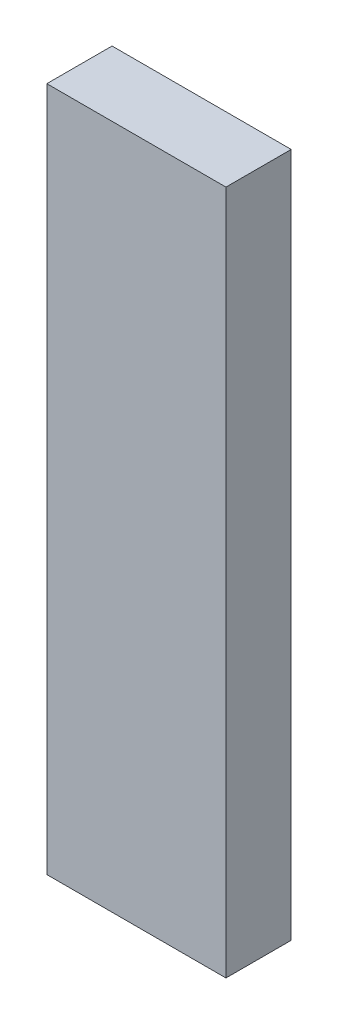
from build123d import *

# Parameters (mm, degrees)
SKETCH1_W           = 17.2974
SKETCH1_H           = 6.2992
BOSS_EXTRUDE1_DEPTH = 66.1416


with BuildPart() as part:
    # Sketch1 → Boss-Extrude1 (new body)
    with BuildSketch(Plane(origin=(0, 0, 0), x_dir=(1, 0, 0), z_dir=(0, 1, 0))):
        Rectangle(SKETCH1_W, SKETCH1_H)
    extrude(amount=BOSS_EXTRUDE1_DEPTH)


solid = part.part
